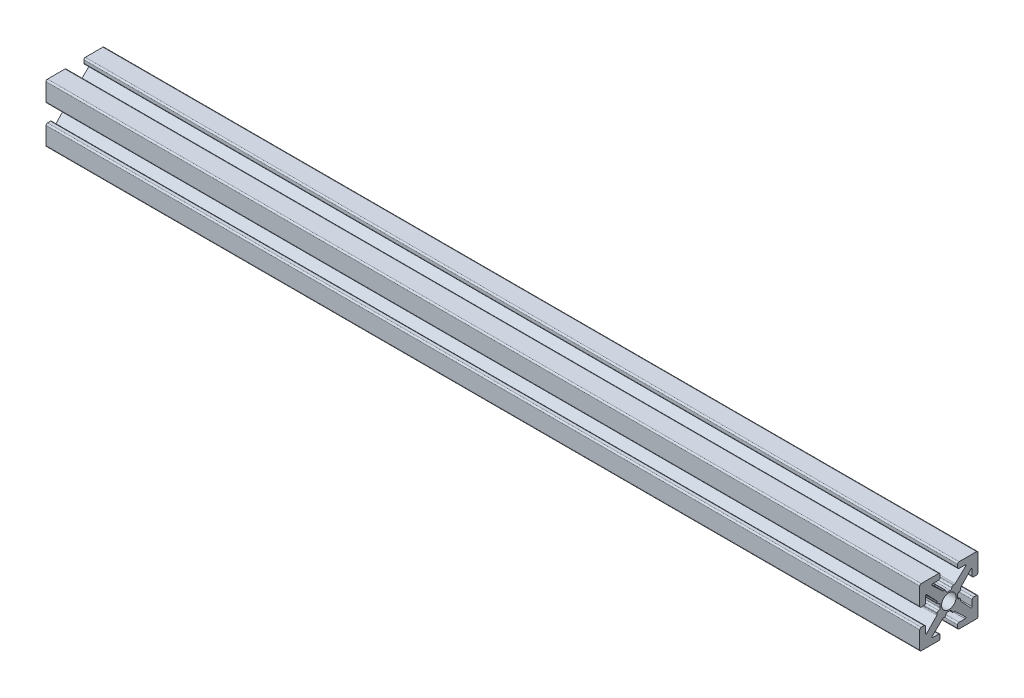
from build123d import *

# Parameters (mm, degrees)
ESTRUSIONE_ESTRUSIONE1_DEPTH = 150
FORO_FILETTATO_M3X0_5_1_D    = 2.5


with BuildPart() as part:
    # Sketch1 → Estrusione-Estrusione1 (new body)
    with BuildSketch(Plane(origin=(0, 0, 0), x_dir=(0, 0, -1), z_dir=(1, 0, 0))):
        with BuildLine():
            Line((-0.2413, 1.4948), (0.2413, 1.4948))
            ThreePointArc((0.2413, 1.4948), (0.420905122, 1.569194878), (0.4953, 1.7488))
            ThreePointArc((0.4953, 1.7488), (0.569694878, 1.928405122), (0.7493, 2.0028))
            Line((0.7493, 2.0028), (0.889923986, 2.0028))
            ThreePointArc((0.889923986, 2.0028), (0.983516259, 2.020671886), (1.063937899, 2.071772548))
            Line((1.063937899, 2.071772548), (2.890793, 3.789886274))
            ThreePointArc((2.890793, 3.789886274), (2.921850101, 3.929196137), (2.803786044, 4.0094))
            Line((2.803786044, 4.0094), (1.7526, 4.0094))
            ThreePointArc((1.7526, 4.0094), (1.572994878, 4.083794878), (1.4986, 4.2634))
            Line((1.4986, 4.2634), (1.4986, 4.746))
            ThreePointArc((1.4986, 4.746), (1.572994878, 4.925605122), (1.7526, 5))
            Line((1.7526, 5), (4.746, 5))
            ThreePointArc((4.746, 5), (4.925605122, 4.925605122), (5, 4.746))
            Line((5, 4.746), (5, 1.7526))
            ThreePointArc((5, 1.7526), (4.925605122, 1.572994878), (4.746, 1.4986))
            Line((4.746, 1.4986), (4.2634, 1.4986))
            ThreePointArc((4.2634, 1.4986), (4.083794878, 1.572994878), (4.0094, 1.7526))
            Line((4.0094, 1.7526), (4.0094, 2.803786044))
            ThreePointArc((4.0094, 2.803786044), (3.929196137, 2.921850101), (3.789886274, 2.890793))
            Line((3.789886274, 2.890793), (2.071772548, 1.063937899))
            ThreePointArc((2.071772548, 1.063937899), (2.020671886, 0.983516259), (2.0028, 0.889923986))
            Line((2.0028, 0.889923986), (2.0028, 0.7493))
            ThreePointArc((2.0028, 0.7493), (1.928405122, 0.569694878), (1.7488, 0.4953))
            ThreePointArc((1.7488, 0.4953), (1.569194878, 0.420905122), (1.4948, 0.2413))
            Line((1.4948, 0.2413), (1.4948, -0.2413))
            ThreePointArc((1.4948, -0.2413), (1.569194878, -0.420905122), (1.7488, -0.4953))
            ThreePointArc((1.7488, -0.4953), (1.928405122, -0.569694878), (2.0028, -0.7493))
            Line((2.0028, -0.7493), (2.0028, -0.889923986))
            ThreePointArc((2.0028, -0.889923986), (2.020671886, -0.983516259), (2.071772548, -1.063937899))
            Line((2.071772548, -1.063937899), (3.789886274, -2.890793))
            ThreePointArc((3.789886274, -2.890793), (3.929196137, -2.921850101), (4.0094, -2.803786044))
            Line((4.0094, -2.803786044), (4.0094, -1.7526))
            ThreePointArc((4.0094, -1.7526), (4.083794878, -1.572994878), (4.2634, -1.4986))
            Line((4.2634, -1.4986), (4.746, -1.4986))
            ThreePointArc((4.746, -1.4986), (4.925605122, -1.572994878), (5, -1.7526))
            Line((5, -1.7526), (5, -4.746))
            ThreePointArc((5, -4.746), (4.925605122, -4.925605122), (4.746, -5))
            Line((4.746, -5), (1.7526, -5))
            ThreePointArc((1.7526, -5), (1.572994878, -4.925605122), (1.4986, -4.746))
            Line((1.4986, -4.746), (1.4986, -4.2634))
            ThreePointArc((1.4986, -4.2634), (1.572994878, -4.083794878), (1.7526, -4.0094))
            Line((1.7526, -4.0094), (2.803786044, -4.0094))
            ThreePointArc((2.803786044, -4.0094), (2.921850101, -3.929196137), (2.890793, -3.789886274))
            Line((2.890793, -3.789886274), (1.063937899, -2.071772548))
            ThreePointArc((1.063937899, -2.071772548), (0.983516259, -2.020671886), (0.889923986, -2.0028))
            Line((0.889923986, -2.0028), (0.7493, -2.0028))
            ThreePointArc((0.7493, -2.0028), (0.569694878, -1.928405122), (0.4953, -1.7488))
            ThreePointArc((0.4953, -1.7488), (0.420905122, -1.569194878), (0.2413, -1.4948))
            Line((0.2413, -1.4948), (-0.2413, -1.4948))
            ThreePointArc((-0.2413, -1.4948), (-0.420905122, -1.569194878), (-0.4953, -1.7488))
            ThreePointArc((-0.4953, -1.7488), (-0.569694878, -1.928405122), (-0.7493, -2.0028))
            Line((-0.7493, -2.0028), (-0.889923986, -2.0028))
            ThreePointArc((-0.889923986, -2.0028), (-0.983516259, -2.020671886), (-1.063937899, -2.071772548))
            Line((-1.063937899, -2.071772548), (-2.890793, -3.789886274))
            ThreePointArc((-2.890793, -3.789886274), (-2.921850101, -3.929196137), (-2.803786044, -4.0094))
            Line((-2.803786044, -4.0094), (-1.7526, -4.0094))
            ThreePointArc((-1.7526, -4.0094), (-1.572994878, -4.083794878), (-1.4986, -4.2634))
            Line((-1.4986, -4.2634), (-1.4986, -4.746))
            ThreePointArc((-1.4986, -4.746), (-1.572994878, -4.925605122), (-1.7526, -5))
            Line((-1.7526, -5), (-4.746, -5))
            ThreePointArc((-4.746, -5), (-4.925605122, -4.925605122), (-5, -4.746))
            Line((-5, -4.746), (-5, -1.7526))
            ThreePointArc((-5, -1.7526), (-4.925605122, -1.572994878), (-4.746, -1.4986))
            Line((-4.746, -1.4986), (-4.2634, -1.4986))
            ThreePointArc((-4.2634, -1.4986), (-4.083794878, -1.572994878), (-4.0094, -1.7526))
            Line((-4.0094, -1.7526), (-4.0094, -2.803786044))
            ThreePointArc((-4.0094, -2.803786044), (-3.929196137, -2.921850101), (-3.789886274, -2.890793))
            Line((-3.789886274, -2.890793), (-2.071772548, -1.063937899))
            ThreePointArc((-2.071772548, -1.063937899), (-2.020671886, -0.983516259), (-2.0028, -0.889923986))
            Line((-2.0028, -0.889923986), (-2.0028, -0.7493))
            ThreePointArc((-2.0028, -0.7493), (-1.928405122, -0.569694878), (-1.7488, -0.4953))
            ThreePointArc((-1.7488, -0.4953), (-1.569194878, -0.420905122), (-1.4948, -0.2413))
            Line((-1.4948, -0.2413), (-1.4948, 0.2413))
            ThreePointArc((-1.4948, 0.2413), (-1.569194878, 0.420905122), (-1.7488, 0.4953))
            ThreePointArc((-1.7488, 0.4953), (-1.928405122, 0.569694878), (-2.0028, 0.7493))
            Line((-2.0028, 0.7493), (-2.0028, 0.889923986))
            ThreePointArc((-2.0028, 0.889923986), (-2.020671886, 0.983516259), (-2.071772548, 1.063937899))
            Line((-2.071772548, 1.063937899), (-3.789886274, 2.890793))
            ThreePointArc((-3.789886274, 2.890793), (-3.929196137, 2.921850101), (-4.0094, 2.803786044))
            Line((-4.0094, 2.803786044), (-4.0094, 1.7526))
            ThreePointArc((-4.0094, 1.7526), (-4.083794878, 1.572994878), (-4.2634, 1.4986))
            Line((-4.2634, 1.4986), (-4.746, 1.4986))
            ThreePointArc((-4.746, 1.4986), (-4.925605122, 1.572994878), (-5, 1.7526))
            Line((-5, 1.7526), (-5, 4.746))
            ThreePointArc((-5, 4.746), (-4.925605122, 4.925605122), (-4.746, 5))
            Line((-4.746, 5), (-1.7526, 5))
            ThreePointArc((-1.7526, 5), (-1.572994878, 4.925605122), (-1.4986, 4.746))
            Line((-1.4986, 4.746), (-1.4986, 4.2634))
            ThreePointArc((-1.4986, 4.2634), (-1.572994878, 4.083794878), (-1.7526, 4.0094))
            Line((-1.7526, 4.0094), (-2.803786044, 4.0094))
            ThreePointArc((-2.803786044, 4.0094), (-2.921850101, 3.929196137), (-2.890793, 3.789886274))
            Line((-2.890793, 3.789886274), (-1.063937899, 2.071772548))
            ThreePointArc((-1.063937899, 2.071772548), (-0.983516259, 2.020671886), (-0.889923986, 2.0028))
            Line((-0.889923986, 2.0028), (-0.7493, 2.0028))
            ThreePointArc((-0.7493, 2.0028), (-0.569694878, 1.928405122), (-0.4953, 1.7488))
            ThreePointArc((-0.4953, 1.7488), (-0.420905122, 1.569194878), (-0.2413, 1.4948))
        make_face()
    extrude(amount=ESTRUSIONE_ESTRUSIONE1_DEPTH)

    # Foro filettato M3x0.5-1 (through all)
    with Locations(Plane.ZY):
        with Locations((0, 0)):
            Hole(FORO_FILETTATO_M3X0_5_1_D / 2)


solid = part.part
